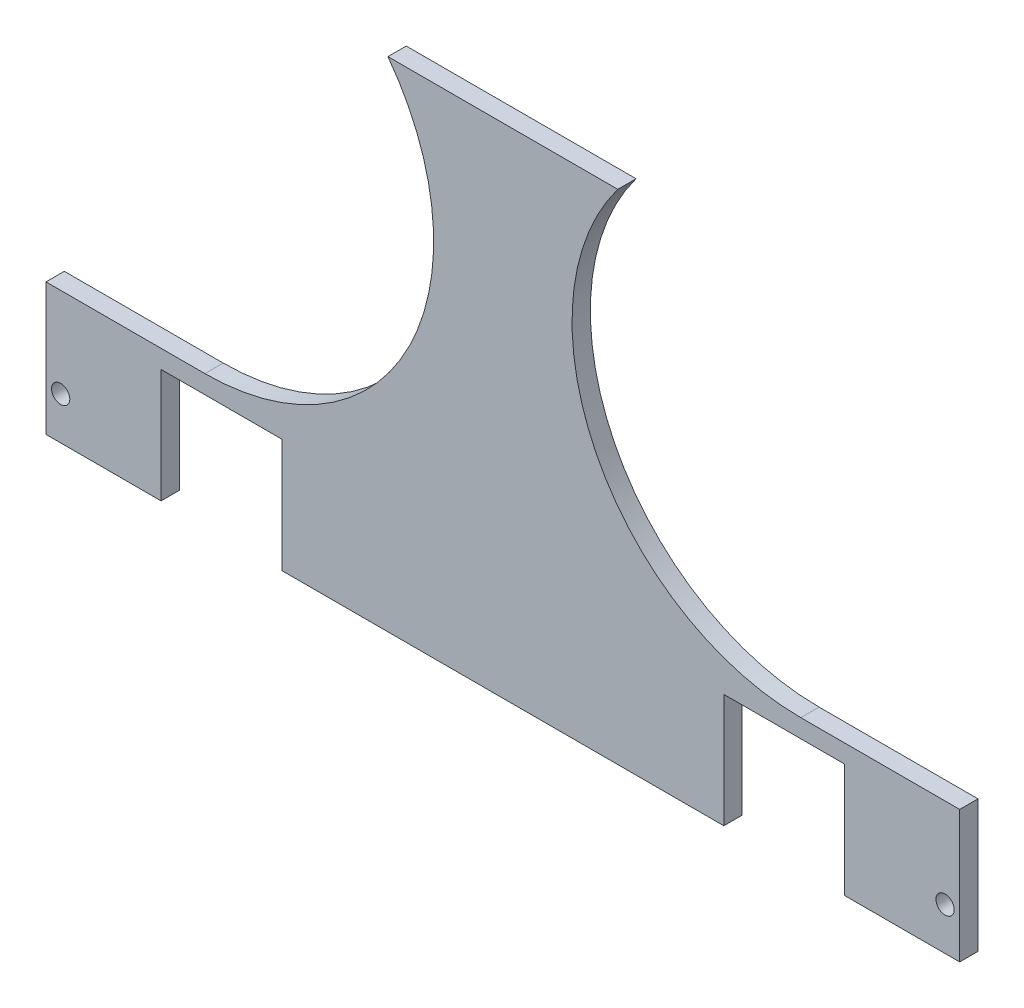
from build123d import *

# Parameters (mm, degrees)
SKETCH1_W           = 249.6
SKETCH1_H           = 267.4
SKETCH1_R           = 2.5
SKETCH1_W_2         = 33
SKETCH1_H_2         = 90
BOSS_EXTRUDE1_DEPTH = 5
SKETCH6_W           = 249.6
SKETCH6_H           = 131.304588604
CUT_EXTRUDE4_DEPTH  = 6


with BuildPart() as part:
    # Sketch1 → Boss-Extrude1 (new body)
    with BuildSketch(Plane.XY):
        with Locations((124.8, -202.7)):
            Rectangle(SKETCH1_W, SKETCH1_H)
        with Locations((245.6, -193.5)):
            Circle(SKETCH1_R, mode=Mode.SUBTRACT)
        with Locations((245.6, -244.5)):
            Circle(SKETCH1_R, mode=Mode.SUBTRACT)
        with Locations((4, -244.5)):
            Circle(SKETCH1_R, mode=Mode.SUBTRACT)
        with Locations((4, -193.5)):
            Circle(SKETCH1_R, mode=Mode.SUBTRACT)
        with Locations((201.66, -219)):
            Rectangle(SKETCH1_W_2, SKETCH1_H_2, mode=Mode.SUBTRACT)
        with Locations((47.94, -219)):
            Rectangle(SKETCH1_W_2, SKETCH1_H_2, mode=Mode.SUBTRACT)
    extrude(amount=BOSS_EXTRUDE1_DEPTH)

    # Sketch6 → Cut-Extrude4 (cut, through all)
    with BuildSketch(Plane.XY.offset(5)):
        with BuildLine():
            Line((43.402860001, -44), (0, -44))
            Line((0, -44), (0, -169))
            Line((0, -169), (43.402860001, -169))
            ThreePointArc((43.402860001, -169), (105.902860001, -106.5), (43.402860001, -44))
        make_face()
        with BuildLine():
            Line((206.197139999, -169), (249.6, -169))
            Line((249.6, -169), (249.6, -44))
            Line((249.6, -44), (206.197139999, -44))
            ThreePointArc((206.197139999, -44), (143.697139999, -106.5), (206.197139999, -169))
        make_face()
        with Locations((124.8, -270.747705698)):
            Rectangle(SKETCH6_W, SKETCH6_H)
    extrude(amount=-CUT_EXTRUDE4_DEPTH, mode=Mode.SUBTRACT)


solid = part.part
